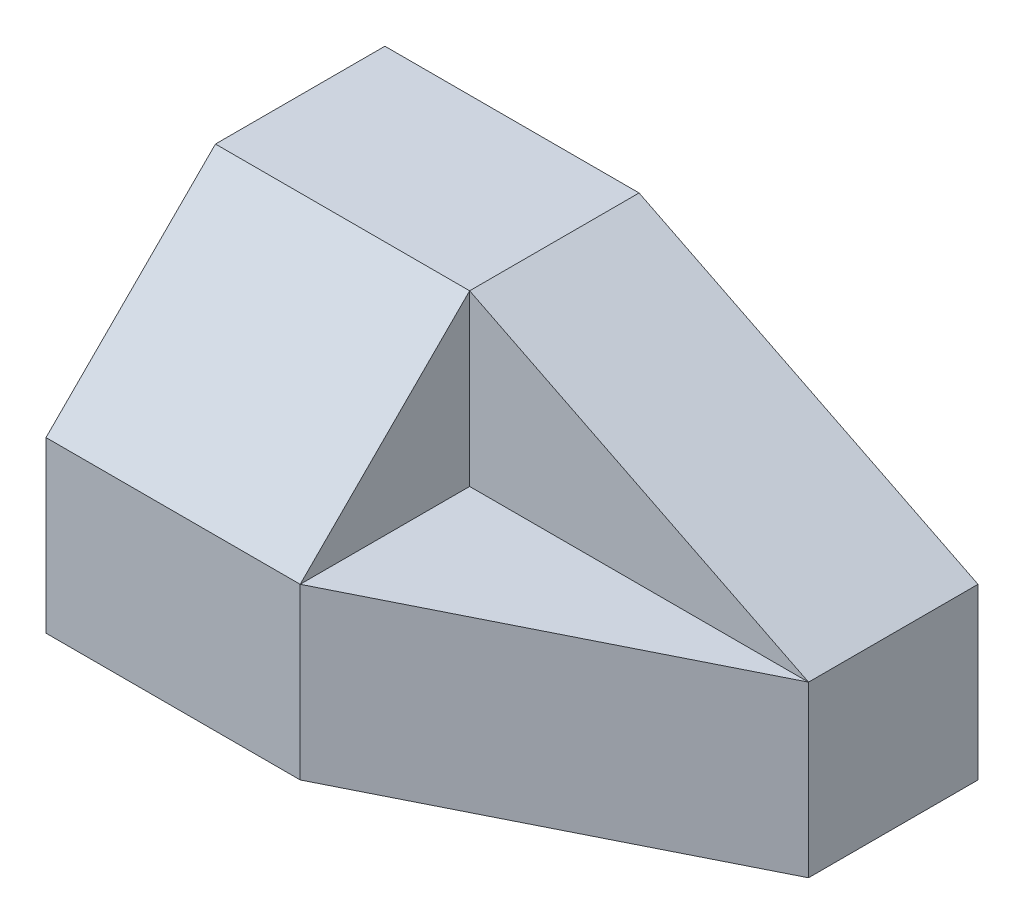
from build123d import *

# Parameters (mm, degrees)
SKETCH1_W                = 177.8
SKETCH1_H                = 101.6
BOSS_EXTRUDE1_DEPTH      = 101.6
CUT_EXTRUDE7_DEPTH       = 1
CUT_EXTRUDE7_DEPTH_BACK  = 76.2
CUT_EXTRUDE10_DEPTH      = 50.8
CUT_EXTRUDE12_DEPTH      = 1
CUT_EXTRUDE12_DEPTH_BACK = 101.6
CUT_EXTRUDE22_DEPTH      = 50.8
CUT_EXTRUDE25_DEPTH      = 50.8


with BuildPart() as part:
    # Sketch1 → Boss-Extrude1 (new body)
    with BuildSketch(Plane(origin=(0, 0, 0), x_dir=(1, 0, 0), z_dir=(0, 1, 0))):
        with Locations((88.9, 50.8)):
            Rectangle(SKETCH1_W, SKETCH1_H)
    extrude(amount=BOSS_EXTRUDE1_DEPTH)

    # Sketch2 → Cut-Extrude7 (cut, two sides)
    with BuildSketch(Plane.ZY) as cut_extrude7_sk:
        Polygon((210.271067812, -159.471067812), (0, 50.8), (-50.8, 101.6), (0, 101.6), (297.368195874, 101.6), (861.537049505, -86.614984162), (774.439921442, -347.686051974), align=None)
    extrude(amount=CUT_EXTRUDE7_DEPTH, mode=Mode.SUBTRACT)
    extrude(cut_extrude7_sk.sketch, amount=-CUT_EXTRUDE7_DEPTH_BACK, mode=Mode.SUBTRACT)

    # Sketch6 → Cut-Extrude10 (cut)
    with BuildSketch(Plane(origin=(0, 0, 0), x_dir=(1, 0, 0), z_dir=(0, 1, 0))):
        Polygon((76.2, 0), (177.8, 50.8), (177.8, 0), align=None)
    extrude(amount=CUT_EXTRUDE10_DEPTH, mode=Mode.SUBTRACT)

    # Sketch8 → Cut-Extrude12 (cut, two sides)
    with BuildSketch(Plane(origin=(0, 101.6, 0), x_dir=(1, 0, 0), z_dir=(0, 1, 0))) as cut_extrude12_sk:
        Polygon((177.8, 50.8), (76.2, 0), (177.8, 0), align=None)
    extrude(amount=CUT_EXTRUDE12_DEPTH, mode=Mode.SUBTRACT)
    extrude(cut_extrude12_sk.sketch, amount=-CUT_EXTRUDE12_DEPTH_BACK, mode=Mode.SUBTRACT)

    # Sketch11 → Cut-Extrude22 (cut)
    with BuildSketch(Plane(origin=(0, 101.6, 0), x_dir=(1, 0, 0), z_dir=(0, 1, 0))):
        Polygon((177.8, 50.8), (76.2, 50.8), (76.2, 0), align=None)
    extrude(amount=-CUT_EXTRUDE22_DEPTH, mode=Mode.SUBTRACT)

    # Sketch15 → Cut-Extrude25 (cut)
    with BuildSketch(Plane.XY.offset(-50.8)):
        Polygon((177.8, 50.8), (76.2, 101.6), (177.8, 101.6), align=None)
    extrude(amount=-CUT_EXTRUDE25_DEPTH, mode=Mode.SUBTRACT)


solid = part.part
